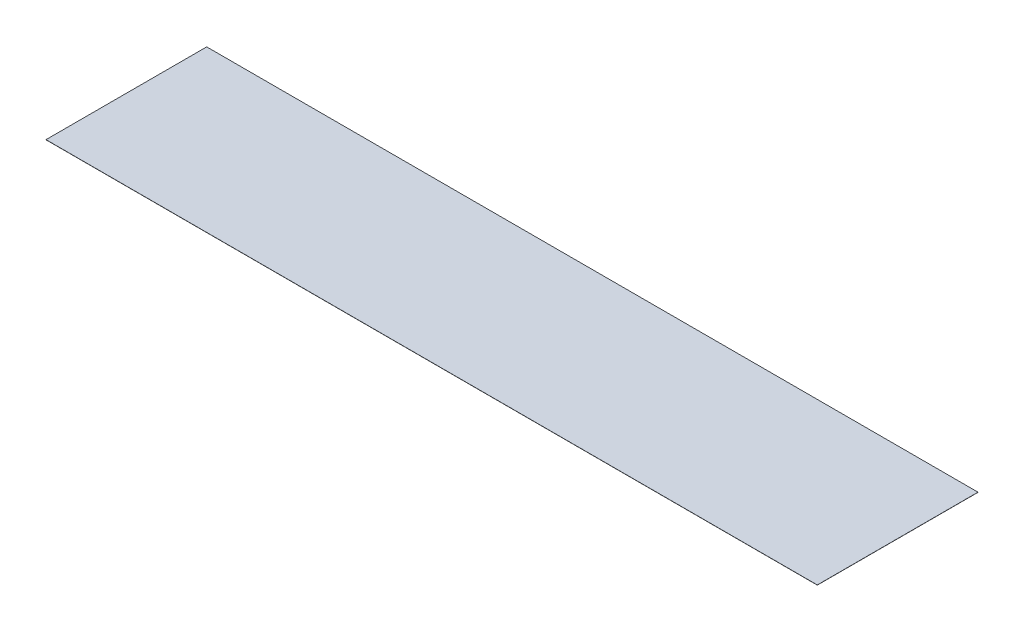
from build123d import *

# Parameters (mm, degrees)
SKETCH1_W           = 21945.6
SKETCH1_H           = 4572
BOSS_EXTRUDE1_DEPTH = 4.7752


with BuildPart() as part:
    # Sketch1 → Boss-Extrude1 (new body)
    with BuildSketch(Plane(origin=(0, 0, 0), x_dir=(1, 0, 0), z_dir=(0, 1, 0))):
        with Locations((0, 2286)):
            Rectangle(SKETCH1_W, SKETCH1_H)
    extrude(amount=BOSS_EXTRUDE1_DEPTH)


solid = part.part
